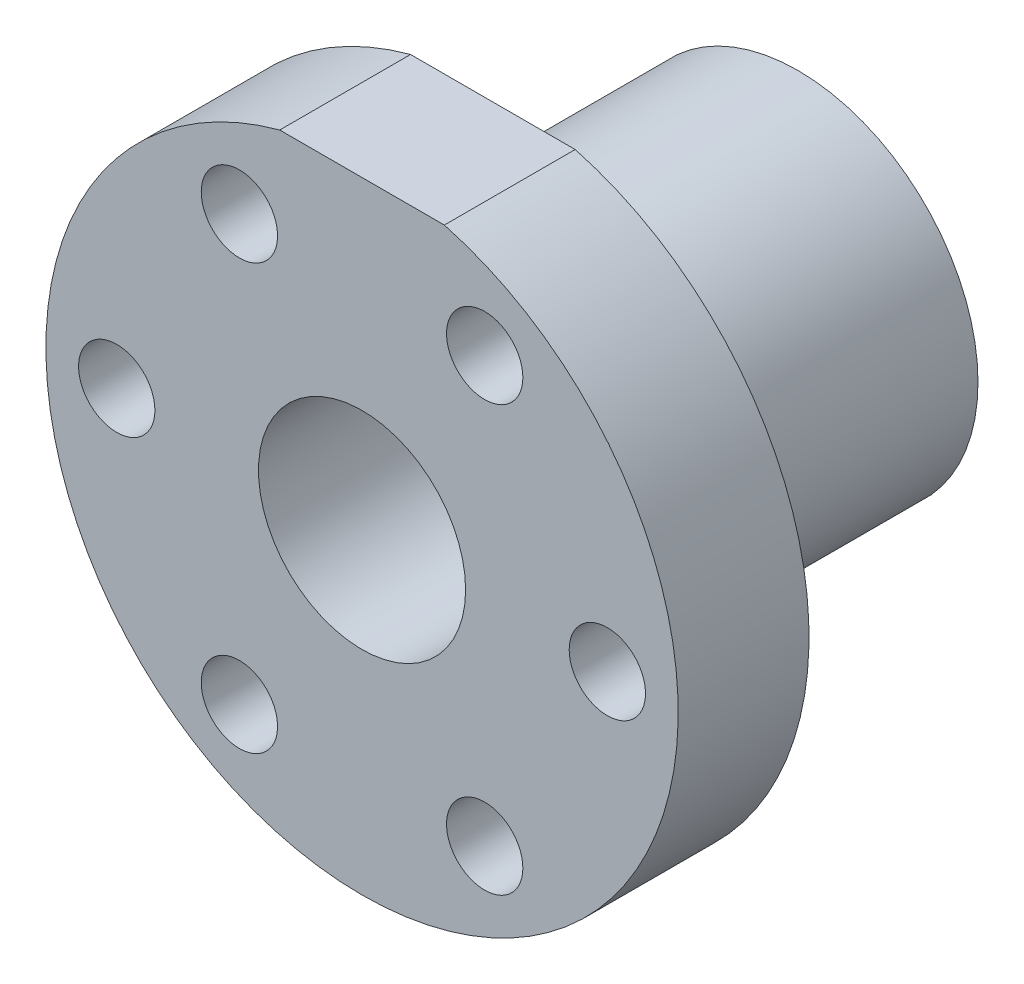
from build123d import *

# Parameters (mm, degrees)
SZKIC1_R                    = 16.5
DODANIE_WYCI_GNI_CIE1_DEPTH = 28
SZKIC2_R                    = 29
DODANIE_WYCI_GNI_CIE2_DEPTH = 12
SZKIC3_R                    = 9.5
WYTNIJ_WYCI_GNI_CIE1_DEPTH  = 40
SZKIC4_W                    = 33.487046283
SZKIC4_H                    = 1
WYTNIJ_WYCI_GNI_CIE2_DEPTH  = 12
SZKIC5_R                    = 3.5
WYTNIJ_WYCI_GNI_CIE3_DEPTH  = 12
SZYK_KO_OWY1_COUNT          = 6


with BuildPart() as part:
    # Szkic1 → Dodanie-wyciągnięcie1 (new body)
    with BuildSketch(Plane.XY):
        Circle(SZKIC1_R)
    extrude(amount=DODANIE_WYCI_GNI_CIE1_DEPTH)

    # Szkic2 → Dodanie-wyciągnięcie2 (add)
    with BuildSketch(Plane.XY.offset(28)):
        Circle(SZKIC2_R)
    extrude(amount=DODANIE_WYCI_GNI_CIE2_DEPTH)

    # Szkic3 → Wytnij-wyciągnięcie1 (cut)
    with BuildSketch(Plane.XY.offset(40)):
        Circle(SZKIC3_R)
    extrude(amount=-WYTNIJ_WYCI_GNI_CIE1_DEPTH, mode=Mode.SUBTRACT)

    # Szkic4 → Wytnij-wyciągnięcie2 (cut)
    with BuildSketch(Plane.XY.offset(40)):
        with Locations((-0.738693263, 28.5)):
            Rectangle(SZKIC4_W, SZKIC4_H)
    extrude(amount=-WYTNIJ_WYCI_GNI_CIE2_DEPTH, mode=Mode.SUBTRACT)

    # Szkic5 → Wytnij-wyciągnięcie3 (cut)
    with BuildSketch(Plane.XY.offset(40)):
        with Locations((-22.5, 0)):
            Circle(SZKIC5_R)
    wytnij_wyci_gni_cie3 = extrude(amount=-WYTNIJ_WYCI_GNI_CIE3_DEPTH, mode=Mode.SUBTRACT)

    # Szyk kołowy1: Wytnij-wyciągnięcie3 ×6 about axis
    szyk_ko_owy1_axis = Axis((0, 0, 0), (0, 0, 1))
    for i in range(1, SZYK_KO_OWY1_COUNT):
        add(wytnij_wyci_gni_cie3.rotate(szyk_ko_owy1_axis, i * 360 / SZYK_KO_OWY1_COUNT), mode=Mode.SUBTRACT)


solid = part.part
